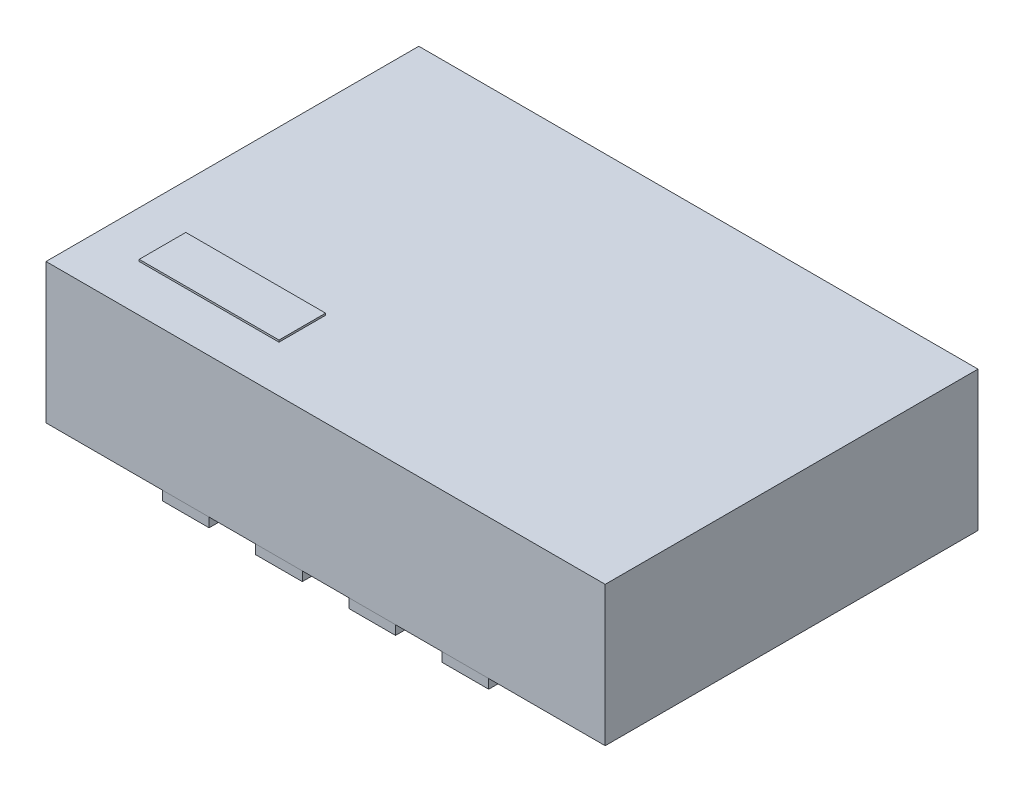
from build123d import *

# Parameters (mm, degrees)
AUFSATZ_LINEAR_AUSTRAGEN1_DEPTH   = 0.05
AUFSATZ_LINEAR_AUSTRAGEN1_2_DEPTH = 0.05
AUFSATZ_LINEAR_AUSTRAGEN1_3_DEPTH = 0.05
AUFSATZ_LINEAR_AUSTRAGEN1_4_DEPTH = 0.05
AUFSATZ_LINEAR_AUSTRAGEN1_5_DEPTH = 0.05
AUFSATZ_LINEAR_AUSTRAGEN1_6_DEPTH = 0.05
AUFSATZ_LINEAR_AUSTRAGEN1_7_DEPTH = 0.05
AUFSATZ_LINEAR_AUSTRAGEN1_8_DEPTH = 0.05
AUFSATZ_LINEAR_AUSTRAGEN1_9_DEPTH = 0.05
SKIZZE2_W                         = 3
SKIZZE2_H                         = 2
AUFSATZ_LINEAR_AUSTRAGEN3_DEPTH   = 0.75
SKIZZE3_W                         = 0.75
SKIZZE3_H                         = 0.25
AUFSATZ_LINEAR_AUSTRAGEN4_DEPTH   = 0.01


with BuildPart() as part:
    # Skizze1 → Aufsatz-Linear austragen1 (new body)
    with BuildSketch(Plane(origin=(0, 0, 0), x_dir=(1, 0, 0), z_dir=(0, 1, 0))):
        with BuildLine():
            Line((-0.908578644, -0.516421356), (-1.041421356, -0.383578644))
            ThreePointArc((-1.041421356, -0.383578644), (-1.084775907, -0.318693974), (-1.1, -0.242157288))
            Line((-1.1, -0.242157288), (-1.1, 0.375))
            ThreePointArc((-1.1, 0.375), (-1.041421356, 0.516421356), (-0.9, 0.575))
            Line((-0.9, 0.575), (0.9, 0.575))
            ThreePointArc((0.9, 0.575), (1.041421356, 0.516421356), (1.1, 0.375))
            Line((1.1, 0.375), (1.1, -0.375))
            ThreePointArc((1.1, -0.375), (1.041421356, -0.516421356), (0.9, -0.575))
            Line((0.9, -0.575), (-0.767157288, -0.575))
            ThreePointArc((-0.767157288, -0.575), (-0.843693974, -0.559775907), (-0.908578644, -0.516421356))
        make_face()
    extrude(amount=AUFSATZ_LINEAR_AUSTRAGEN1_DEPTH)


with BuildPart() as body_2:
    # Skizze1 → Aufsatz-Linear austragen1 2 (new body)
    with BuildSketch(Plane(origin=(0, 0, 0), x_dir=(1, 0, 0), z_dir=(0, 1, 0))):
        with BuildLine():
            Line((-0.255, -0.65), (-0.245, -0.65))
            ThreePointArc((-0.245, -0.65), (-0.160147186, -0.685147186), (-0.125, -0.77))
            Line((-0.125, -0.77), (-0.125, -1))
            Line((-0.125, -1), (-0.375, -1))
            Line((-0.375, -1), (-0.375, -0.77))
            ThreePointArc((-0.375, -0.77), (-0.339852814, -0.685147186), (-0.255, -0.65))
        make_face()
    extrude(amount=AUFSATZ_LINEAR_AUSTRAGEN1_2_DEPTH)


with BuildPart() as body_3:
    # Skizze1 → Aufsatz-Linear austragen1 3 (new body)
    with BuildSketch(Plane(origin=(0, 0, 0), x_dir=(1, 0, 0), z_dir=(0, 1, 0))):
        with BuildLine():
            Line((0.125, -1), (0.375, -1))
            Line((0.375, -1), (0.375, -0.77))
            ThreePointArc((0.375, -0.77), (0.339852814, -0.685147186), (0.255, -0.65))
            Line((0.255, -0.65), (0.245, -0.65))
            ThreePointArc((0.245, -0.65), (0.160147186, -0.685147186), (0.125, -0.77))
            Line((0.125, -0.77), (0.125, -1))
        make_face()
    extrude(amount=AUFSATZ_LINEAR_AUSTRAGEN1_3_DEPTH)


with BuildPart() as body_4:
    # Skizze1 → Aufsatz-Linear austragen1 4 (new body)
    with BuildSketch(Plane(origin=(0, 0, 0), x_dir=(1, 0, 0), z_dir=(0, 1, 0))):
        with BuildLine():
            Line((0.625, -1), (0.875, -1))
            Line((0.875, -1), (0.875, -0.77))
            ThreePointArc((0.875, -0.77), (0.839852814, -0.685147186), (0.755, -0.65))
            Line((0.755, -0.65), (0.745, -0.65))
            ThreePointArc((0.745, -0.65), (0.660147186, -0.685147186), (0.625, -0.77))
            Line((0.625, -0.77), (0.625, -1))
        make_face()
    extrude(amount=AUFSATZ_LINEAR_AUSTRAGEN1_4_DEPTH)


with BuildPart() as body_5:
    # Skizze1 → Aufsatz-Linear austragen1 5 (new body)
    with BuildSketch(Plane(origin=(0, 0, 0), x_dir=(1, 0, 0), z_dir=(0, 1, 0))):
        with BuildLine():
            Line((-0.625, -1), (-0.875, -1))
            Line((-0.875, -1), (-0.875, -0.77))
            ThreePointArc((-0.875, -0.77), (-0.839852814, -0.685147186), (-0.755, -0.65))
            Line((-0.755, -0.65), (-0.745, -0.65))
            ThreePointArc((-0.745, -0.65), (-0.660147186, -0.685147186), (-0.625, -0.77))
            Line((-0.625, -0.77), (-0.625, -1))
        make_face()
    extrude(amount=AUFSATZ_LINEAR_AUSTRAGEN1_5_DEPTH)


with BuildPart() as body_6:
    # Skizze1 → Aufsatz-Linear austragen1 6 (new body)
    with BuildSketch(Plane(origin=(0, 0, 0), x_dir=(1, 0, 0), z_dir=(0, 1, 0))):
        with BuildLine():
            Line((-0.375, 1), (-0.125, 1))
            Line((-0.125, 1), (-0.125, 0.77))
            ThreePointArc((-0.125, 0.77), (-0.160147186, 0.685147186), (-0.245, 0.65))
            Line((-0.245, 0.65), (-0.255, 0.65))
            ThreePointArc((-0.255, 0.65), (-0.339852814, 0.685147186), (-0.375, 0.77))
            Line((-0.375, 0.77), (-0.375, 1))
        make_face()
    extrude(amount=AUFSATZ_LINEAR_AUSTRAGEN1_6_DEPTH)


with BuildPart() as body_7:
    # Skizze1 → Aufsatz-Linear austragen1 7 (new body)
    with BuildSketch(Plane(origin=(0, 0, 0), x_dir=(1, 0, 0), z_dir=(0, 1, 0))):
        with BuildLine():
            Line((-0.745, 0.65), (-0.755, 0.65))
            ThreePointArc((-0.755, 0.65), (-0.839852814, 0.685147186), (-0.875, 0.77))
            Line((-0.875, 0.77), (-0.875, 1))
            Line((-0.875, 1), (-0.625, 1))
            Line((-0.625, 1), (-0.625, 0.77))
            ThreePointArc((-0.625, 0.77), (-0.660147186, 0.685147186), (-0.745, 0.65))
        make_face()
    extrude(amount=AUFSATZ_LINEAR_AUSTRAGEN1_7_DEPTH)


with BuildPart() as body_8:
    # Skizze1 → Aufsatz-Linear austragen1 8 (new body)
    with BuildSketch(Plane(origin=(0, 0, 0), x_dir=(1, 0, 0), z_dir=(0, 1, 0))):
        with BuildLine():
            Line((0.245, 0.65), (0.255, 0.65))
            ThreePointArc((0.255, 0.65), (0.339852814, 0.685147186), (0.375, 0.77))
            Line((0.375, 0.77), (0.375, 1))
            Line((0.375, 1), (0.125, 1))
            Line((0.125, 1), (0.125, 0.77))
            ThreePointArc((0.125, 0.77), (0.160147186, 0.685147186), (0.245, 0.65))
        make_face()
    extrude(amount=AUFSATZ_LINEAR_AUSTRAGEN1_8_DEPTH)


with BuildPart() as body_9:
    # Skizze1 → Aufsatz-Linear austragen1 9 (new body)
    with BuildSketch(Plane(origin=(0, 0, 0), x_dir=(1, 0, 0), z_dir=(0, 1, 0))):
        with BuildLine():
            Line((0.745, 0.65), (0.755, 0.65))
            ThreePointArc((0.755, 0.65), (0.839852814, 0.685147186), (0.875, 0.77))
            Line((0.875, 0.77), (0.875, 1))
            Line((0.875, 1), (0.625, 1))
            Line((0.625, 1), (0.625, 0.77))
            ThreePointArc((0.625, 0.77), (0.660147186, 0.685147186), (0.745, 0.65))
        make_face()
    extrude(amount=AUFSATZ_LINEAR_AUSTRAGEN1_9_DEPTH)


with BuildPart() as body_10:
    # Skizze2 → Aufsatz-Linear austragen3 (new body)
    with BuildSketch(Plane(origin=(0, 0.05, 0), x_dir=(1, 0, 0), z_dir=(0, 1, 0))):
        Rectangle(SKIZZE2_W, SKIZZE2_H)
    extrude(amount=AUFSATZ_LINEAR_AUSTRAGEN3_DEPTH)

    # Skizze3 → Aufsatz-Linear austragen4 (add)
    with BuildSketch(Plane(origin=(0, 0.8, 0), x_dir=(1, 0, 0), z_dir=(0, 1, 0))):
        with Locations((-0.875, -0.625)):
            Rectangle(SKIZZE3_W, SKIZZE3_H)
    extrude(amount=AUFSATZ_LINEAR_AUSTRAGEN4_DEPTH)


solid = Compound([part.part, body_2.part, body_3.part, body_4.part, body_5.part, body_6.part, body_7.part, body_8.part, body_9.part, body_10.part])
